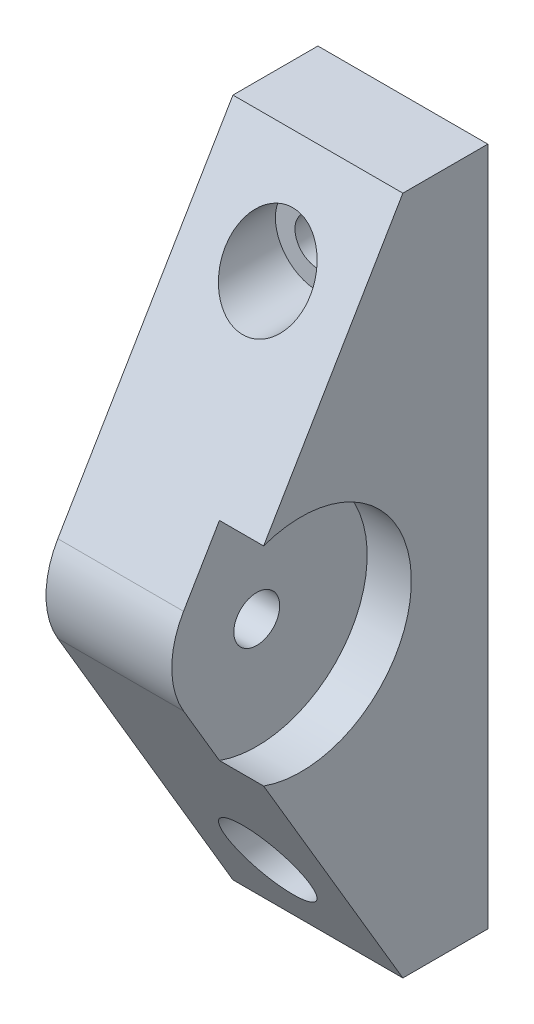
from build123d import *

# Parameters (mm, degrees)
SKETCH1_W           = 20
SKETCH1_H           = 80
SKETCH1_R           = 2.7
BOSS_EXTRUDE1_DEPTH = 10
SKETCH2_R           = 2.7
BOSS_EXTRUDE2_DEPTH = 10
SKETCH3_R           = 5
CUT_EXTRUDE1_DEPTH  = 75.054034326
SKETCH4_R           = 13
CUT_EXTRUDE2_DEPTH  = 5.2


with BuildPart() as part:
    # Sketch1 → Boss-Extrude1 (new body)
    with BuildSketch(Plane.XY):
        with Locations((0, -30)):
            Rectangle(SKETCH1_W, SKETCH1_H)
        Circle(SKETCH1_R, mode=Mode.SUBTRACT)
        with Locations((0, -60)):
            Circle(SKETCH1_R, mode=Mode.SUBTRACT)
    extrude(amount=BOSS_EXTRUDE1_DEPTH)

    # Sketch2 → Boss-Extrude2 (add, symmetric)
    with BuildSketch(Plane(origin=(0, 0, 0), x_dir=(0, 0, -1), z_dir=(1, 0, 0))):
        with BuildLine():
            Line((-10, 10), (-30.611529786, -24.916541064))
            ThreePointArc((-30.611529786, -24.916541064), (-32, -30), (-30.611529786, -35.083458936))
            Line((-30.611529786, -35.083458936), (-10, -70))
            Line((-10, -70), (-10, 10))
        make_face()
        with Locations((-22, -30)):
            Circle(SKETCH2_R, mode=Mode.SUBTRACT)
    extrude(amount=BOSS_EXTRUDE2_DEPTH, both=True)

    # Sketch3 → Cut-Extrude1 (cut, through all)
    with BuildSketch(Plane(origin=(0, 0, 10), x_dir=(-1, 0, 0), z_dir=(0, 0, -1))):
        with Locations((0, -60)):
            Circle(SKETCH3_R)
        Circle(SKETCH3_R)
    extrude(amount=-CUT_EXTRUDE1_DEPTH, mode=Mode.SUBTRACT)

    # Sketch4 → Cut-Extrude2 (cut)
    with BuildSketch(Plane(origin=(10, 0, 0), x_dir=(0, 0, -1), z_dir=(1, 0, 0))):
        with Locations((-22, -30)):
            Circle(SKETCH4_R)
    extrude(amount=-CUT_EXTRUDE2_DEPTH, mode=Mode.SUBTRACT)


solid = part.part
